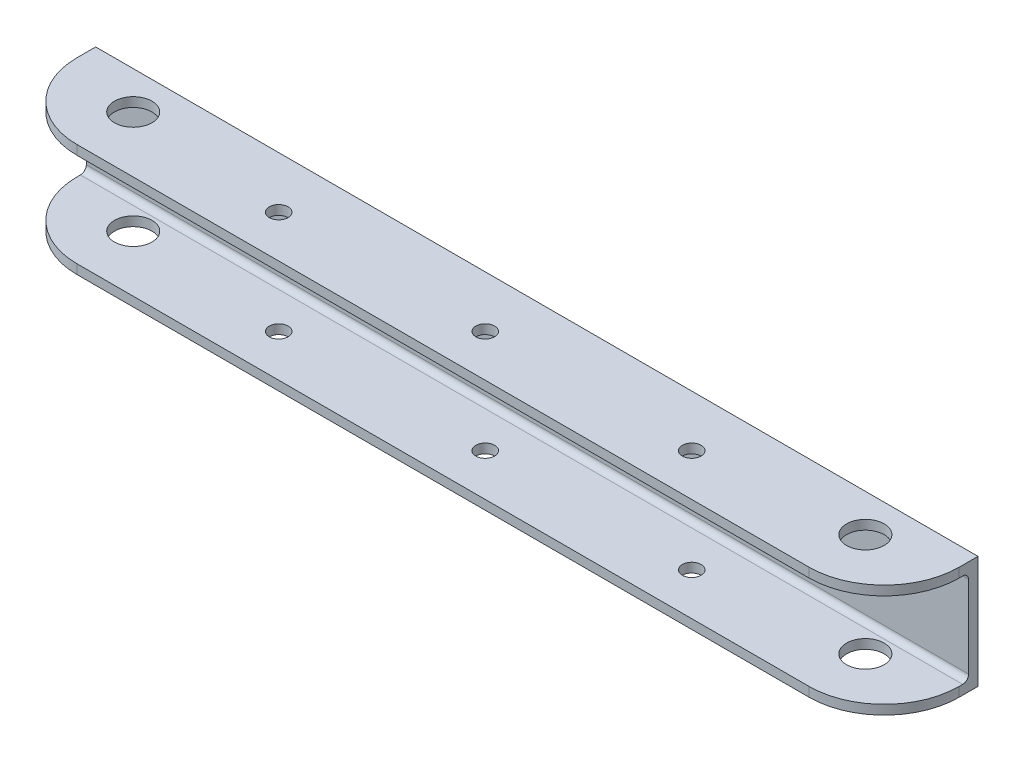
from build123d import *

# Parameters (mm, degrees)
SKETCH1_W           = 50.8
SKETCH1_H           = 38.1
SKETCH1_W_2         = 196.85
BOSS_EXTRUDE1_DEPTH = 31.75
SKETCH2_W           = 28.575
SKETCH2_H           = 31.75
CUT_EXTRUDE1_DEPTH  = 299.45
SKETCH3_R           = 6.35
CUT_EXTRUDE2_DEPTH  = 39.1
FILLET1_R           = 25.4
SKETCH4_R           = 3.175
CUT_EXTRUDE3_DEPTH  = 39.1
FILLET2_R           = 2


with BuildPart() as part:
    # Sketch1 → Boss-Extrude1 (new body)
    with BuildSketch(Plane.XY):
        with Locations((-561.325887252, 19.05)):
            Rectangle(SKETCH1_W, SKETCH1_H)
        with Locations((-437.500887252, 19.05)):
            Rectangle(SKETCH1_W_2, SKETCH1_H)
        with Locations((-313.675887252, 19.05)):
            Rectangle(SKETCH1_W, SKETCH1_H)
    extrude(amount=BOSS_EXTRUDE1_DEPTH)

    # Sketch2 → Cut-Extrude1 (cut, through all)
    with BuildSketch(Plane.ZY.offset(586.725887252)):
        with Locations((17.4625, 19.05)):
            Rectangle(SKETCH2_W, SKETCH2_H)
    extrude(amount=-CUT_EXTRUDE1_DEPTH, mode=Mode.SUBTRACT)

    # Sketch3 → Cut-Extrude2 (cut, through all)
    with BuildSketch(Plane.XZ):
        with Locations((-561.325887252, 12.7)):
            Circle(SKETCH3_R)
        with Locations((-313.675887252, 12.7)):
            Circle(SKETCH3_R)
    extrude(amount=-CUT_EXTRUDE2_DEPTH, mode=Mode.SUBTRACT)

    # Fillet1
    fillet1_edges = [part.edges().sort_by_distance(p)[0] for p in [
        (-586.725887252, 36.5125, 31.75),
        (-288.275887252, 1.5875, 31.75),
        (-288.275887252, 36.5125, 31.75),
        (-586.725887252, 1.5875, 31.75),
    ]]
    fillet(fillet1_edges, radius=FILLET1_R)

    # Sketch4 → Cut-Extrude3 (cut, through all)
    with BuildSketch(Plane.XZ):
        with Locations((-507.350887252, 17.4625)):
            Circle(SKETCH4_R)
        with Locations((-437.500887252, 17.4625)):
            Circle(SKETCH4_R)
        with Locations((-367.650887252, 17.4625)):
            Circle(SKETCH4_R)
    extrude(amount=-CUT_EXTRUDE3_DEPTH, mode=Mode.SUBTRACT)

    # Fillet2
    fillet2_edges = [part.edges().sort_by_distance(p)[0] for p in [
        (-437.500887252, 3.175, 3.175),
        (-437.500887252, 34.925, 3.175),
    ]]
    fillet(fillet2_edges, radius=FILLET2_R)


solid = part.part
